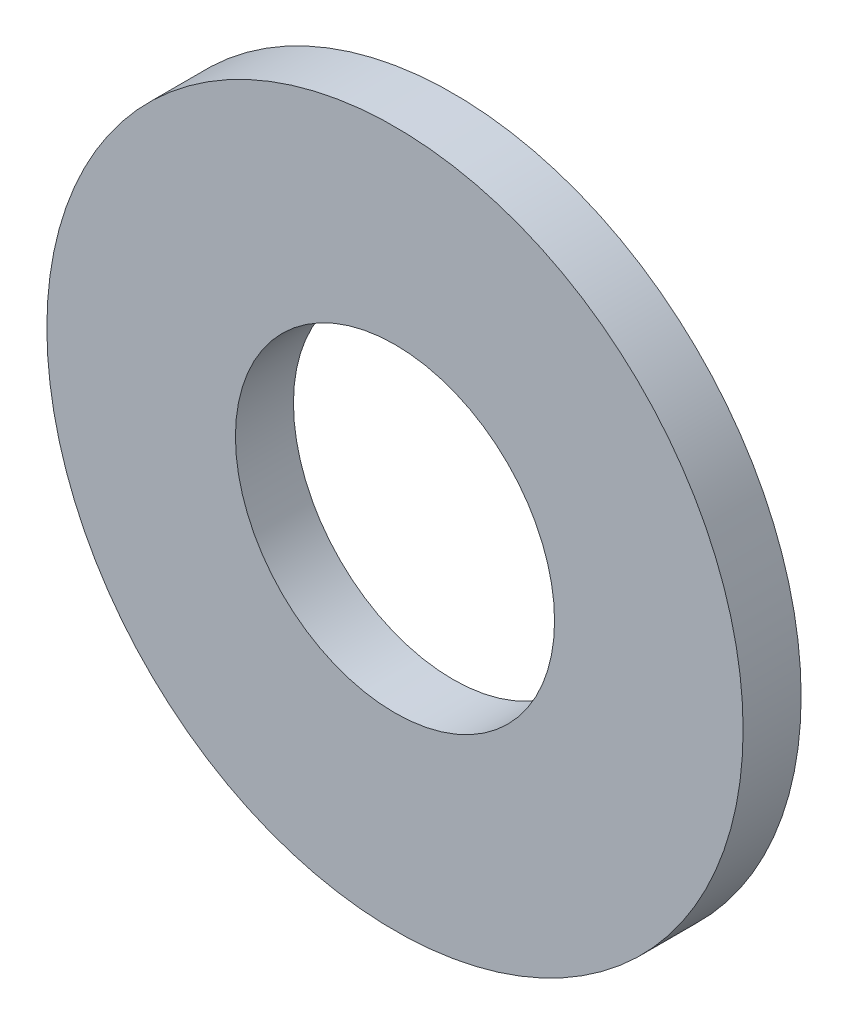
from build123d import *

# Parameters (mm, degrees)
SKETCH1_R           = 6
SKETCH1_R_2         = 2.75
BOSS_EXTRUDE1_DEPTH = 1


with BuildPart() as part:
    # Sketch1 → Boss-Extrude1 (new body)
    with BuildSketch(Plane.XY):
        Circle(SKETCH1_R)
        Circle(SKETCH1_R_2, mode=Mode.SUBTRACT)
    extrude(amount=BOSS_EXTRUDE1_DEPTH)


solid = part.part
